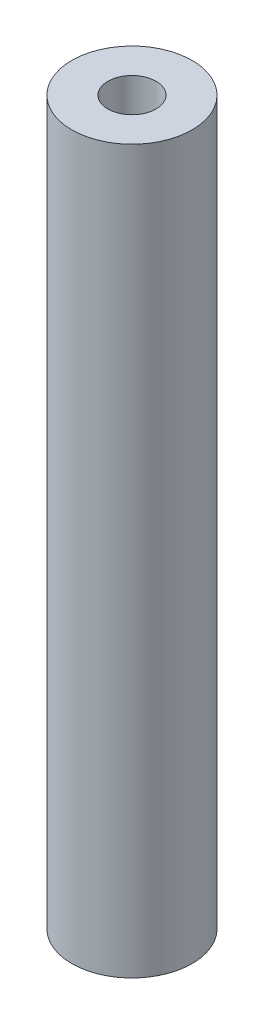
from build123d import *

# Parameters (mm, degrees)
SKETCH1_R           = 2.5
SKETCH1_R_2         = 1
BOSS_EXTRUDE1_DEPTH = 30


with BuildPart() as part:
    # Sketch1 → Boss-Extrude1 (new body)
    with BuildSketch(Plane(origin=(0, 0, 0), x_dir=(1, 0, 0), z_dir=(0, 1, 0))):
        Circle(SKETCH1_R)
        Circle(SKETCH1_R_2, mode=Mode.SUBTRACT)
    extrude(amount=BOSS_EXTRUDE1_DEPTH)


solid = part.part
